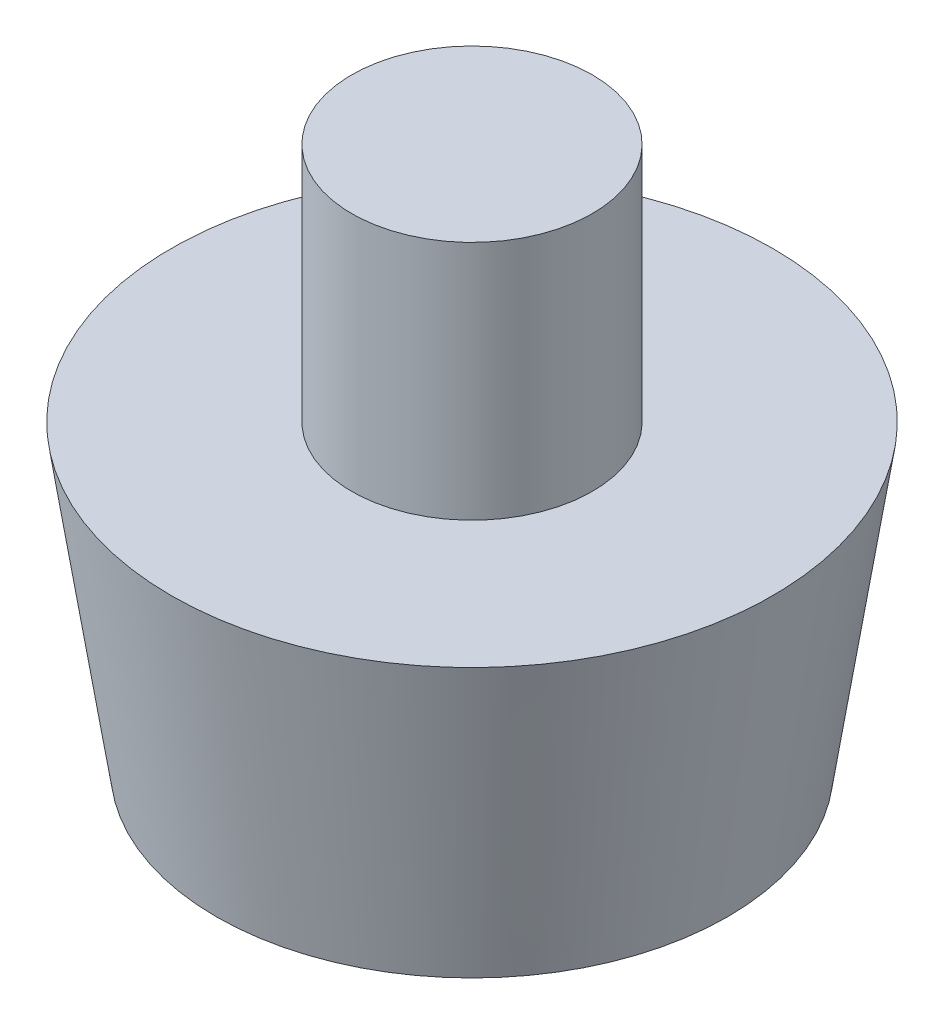
from build123d import *


with BuildPart() as part:
    # Sketch1 → Revolve1 (revolve)
    with BuildSketch(Plane.XY):
        Polygon((0, 2), (-3, 2), (-3, 4.5), (-4, 4.5), (-4, 0), (-8.5, 0), (-10, 10), (-4, 10), (-4, 18), (0, 18), align=None)
    revolve(axis=Axis((0, 0, 0), (0, 1, 0)))


solid = part.part
